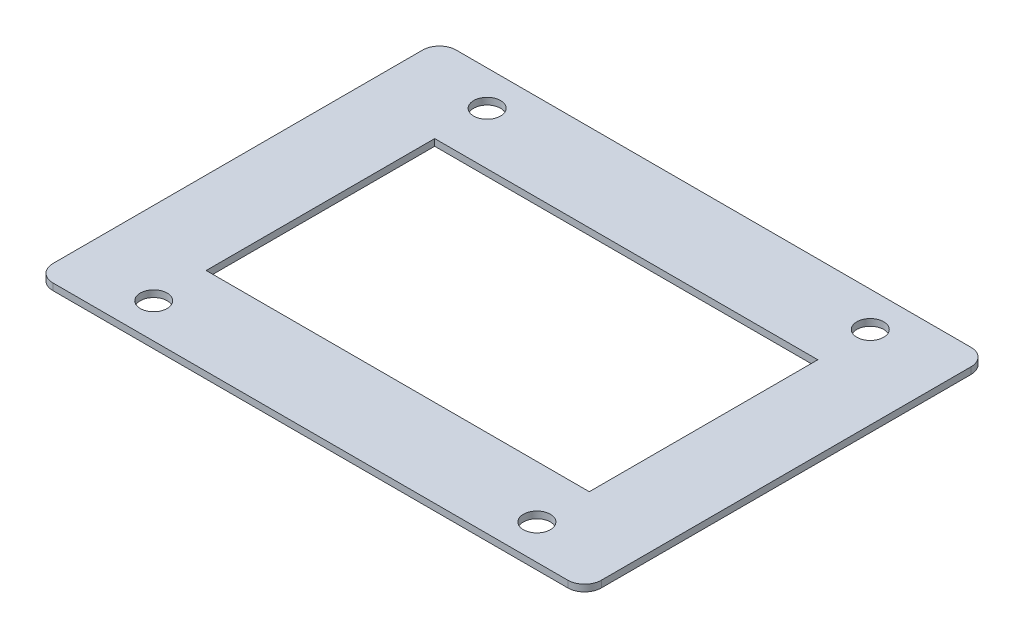
from build123d import *

# Parameters (mm, degrees)
CROQUIS1_R              = 2
SALIENTE_EXTRUIR2_DEPTH = 1
CORTAR_EXTRUIR2_REACH   = 3


with BuildPart() as part:
    # Croquis1 → Saliente-Extruir2 (new body)
    with BuildSketch(Plane(origin=(0, 0, 0), x_dir=(1, 0, 0), z_dir=(0, 1, 0))):
        with BuildLine():
            Line((40.8, 27.5), (40.8, -27.5))
            ThreePointArc((40.8, -27.5), (40.067766953, -29.267766953), (38.3, -30))
            Line((38.3, -30), (-38.3, -30))
            ThreePointArc((-38.3, -30), (-40.067766953, -29.267766953), (-40.8, -27.5))
            Line((-40.8, -27.5), (-40.8, 27.5))
            ThreePointArc((-40.8, 27.5), (-40.067766953, 29.267766953), (-38.3, 30))
            Line((-38.3, 30), (38.3, 30))
            ThreePointArc((38.3, 30), (40.067766953, 29.267766953), (40.8, 27.5))
        make_face()
        with Locations((28.5, -24.8)):
            Circle(CROQUIS1_R, mode=Mode.SUBTRACT)
        with Locations((28.5, 24.8)):
            Circle(CROQUIS1_R, mode=Mode.SUBTRACT)
        with Locations((-28.5, 24.8)):
            Circle(CROQUIS1_R, mode=Mode.SUBTRACT)
        with Locations((-28.5, -24.8)):
            Circle(CROQUIS1_R, mode=Mode.SUBTRACT)
    extrude(amount=SALIENTE_EXTRUIR2_DEPTH)

    # Croquis2 → Cortar-Extruir2 (cut, up to next)
    with BuildSketch(Plane(origin=(0, 0, 0), x_dir=(1, 0, 0), z_dir=(0, 1, 0)), mode=Mode.PRIVATE) as cortar_extruir2_sk1:
        Polygon((-28.5, 17), (28.5, 17), (28.5, -17), (-28.5, -17), (-28.5, -4), align=None)
    cortar_extruir2_tool1 = extrude(cortar_extruir2_sk1.sketch, amount=CORTAR_EXTRUIR2_REACH, mode=Mode.PRIVATE) & part.part
    add(cortar_extruir2_tool1.solids().sort_by_distance((0, 0, 0))[0], mode=Mode.SUBTRACT)


solid = part.part
